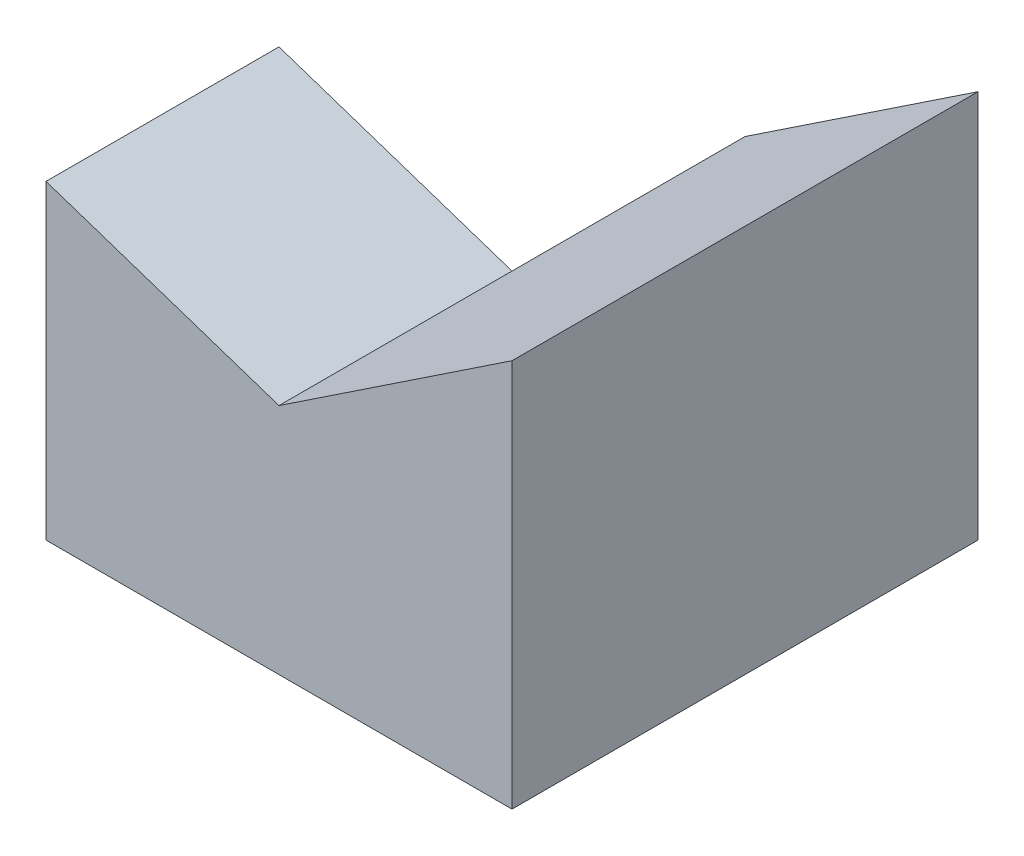
from build123d import *

# Parameters (mm, degrees)
SKETCH1_W           = 6
SKETCH1_H           = 6
BOSS_EXTRUDE1_DEPTH = 5
CUT_EXTRUDE3_DEPTH  = 13.5
CUT_EXTRUDE4_DEPTH  = 3


with BuildPart() as part:
    # Sketch1 → Boss-Extrude1 (new body)
    with BuildSketch(Plane(origin=(0, 0, 0), x_dir=(1, 0, 0), z_dir=(0, 1, 0))):
        Rectangle(SKETCH1_W, SKETCH1_H)
    extrude(amount=BOSS_EXTRUDE1_DEPTH)

    # Sketch5 → Cut-Extrude3 (cut)
    with BuildSketch(Plane.XY.offset(3)):
        Polygon((-3, 5), (0, 3), (3, 5), align=None)
        Polygon((0, 3), (-3, 5), (-3, 4), align=None)
    extrude(amount=-CUT_EXTRUDE3_DEPTH, mode=Mode.SUBTRACT)

    # Sketch7 → Cut-Extrude4 (cut)
    with BuildSketch(Plane(origin=(0, 0, -3), x_dir=(-1, 0, 0), z_dir=(0, 0, -1))):
        Polygon((0, 3), (3, 0), (3, 6), align=None)
    extrude(amount=-CUT_EXTRUDE4_DEPTH, mode=Mode.SUBTRACT)


solid = part.part
